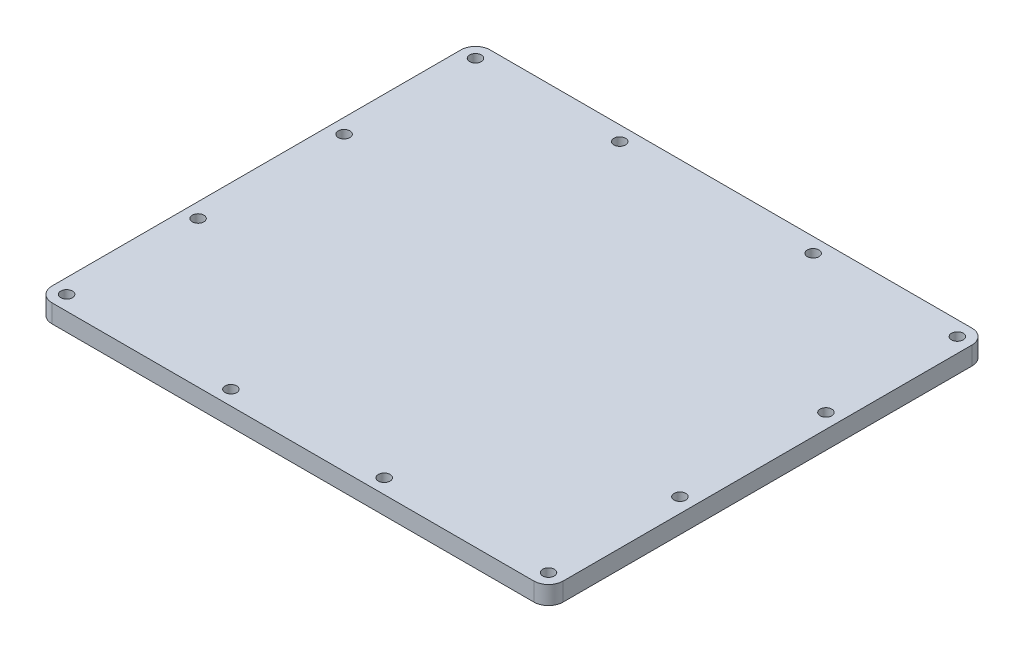
from build123d import *

# Parameters (mm, degrees)
SKETCH1_R           = 1.6
BOSS_EXTRUDE1_DEPTH = 5


with BuildPart() as part:
    # Sketch1 → Boss-Extrude1 (new body)
    with BuildSketch(Plane(origin=(0, 0, 0), x_dir=(1, 0, 0), z_dir=(0, 1, 0))):
        with BuildLine():
            Line((-66, -60), (66, -60))
            ThreePointArc((66, -60), (68.828427125, -58.828427125), (70, -56))
            Line((70, -56), (70, 56))
            ThreePointArc((70, 56), (68.828427125, 58.828427125), (66, 60))
            Line((66, 60), (-66, 60))
            ThreePointArc((-66, 60), (-68.828427125, 58.828427125), (-70, 56))
            Line((-70, 56), (-70, -56))
            ThreePointArc((-70, -56), (-68.828427125, -58.828427125), (-66, -60))
        make_face()
        with Locations((-66, 56)):
            Circle(SKETCH1_R, mode=Mode.SUBTRACT)
        with Locations((-66, -56)):
            Circle(SKETCH1_R, mode=Mode.SUBTRACT)
        with Locations((66, -56)):
            Circle(SKETCH1_R, mode=Mode.SUBTRACT)
        with Locations((66, 56)):
            Circle(SKETCH1_R, mode=Mode.SUBTRACT)
        with Locations((-66, -20)):
            Circle(SKETCH1_R, mode=Mode.SUBTRACT)
        with Locations((66, -20)):
            Circle(SKETCH1_R, mode=Mode.SUBTRACT)
        with Locations((-66, 20)):
            Circle(SKETCH1_R, mode=Mode.SUBTRACT)
        with Locations((66, 20)):
            Circle(SKETCH1_R, mode=Mode.SUBTRACT)
        with Locations((-21, -56)):
            Circle(SKETCH1_R, mode=Mode.SUBTRACT)
        with Locations((21, -56)):
            Circle(SKETCH1_R, mode=Mode.SUBTRACT)
        with Locations((-26.5, 56)):
            Circle(SKETCH1_R, mode=Mode.SUBTRACT)
        with Locations((26.5, 56)):
            Circle(SKETCH1_R, mode=Mode.SUBTRACT)
    extrude(amount=BOSS_EXTRUDE1_DEPTH)


solid = part.part
